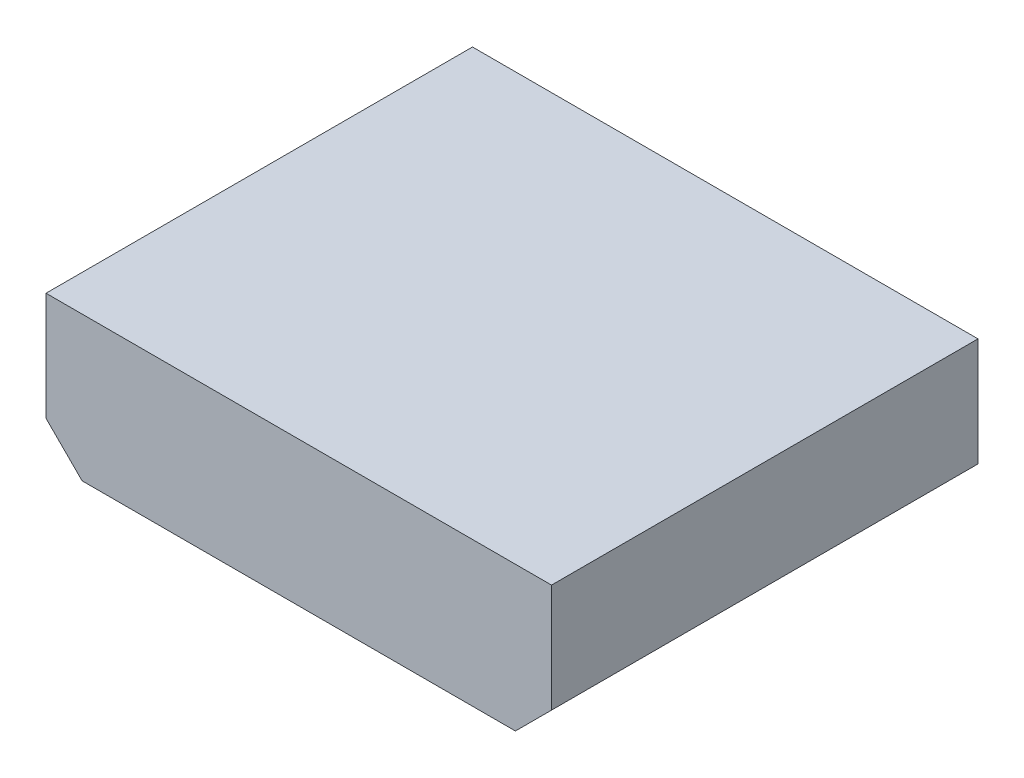
from build123d import *

# Parameters (mm, degrees)
COMPONENT_OUTLINE_DEPTH = 15
SKETCH2_R               = 0.25
EXTRUDE_1_DEPTH         = 2
SKETCH3_R               = 0.25
EXTRUDE_2_DEPTH         = 2
SKETCH4_R               = 0.25
EXTRUDE_3_DEPTH         = 2
SKETCH5_R               = 0.25
EXTRUDE_4_DEPTH         = 2


with BuildPart() as part:
    # Sketch1 → Component_Outline (new body)
    with BuildSketch(Plane.XY):
        Polygon((-5.08, 2.54), (-5.08, -1.27), (-3.81, -2.54), (11.43, -2.54), (12.7, -1.27), (12.7, 2.54), align=None)
    extrude(amount=COMPONENT_OUTLINE_DEPTH)


with BuildPart() as body_2:
    # Sketch2 → Extrude 1 (new body)
    with BuildSketch(Plane.XY):
        Circle(SKETCH2_R)
    extrude(amount=-EXTRUDE_1_DEPTH)


with BuildPart() as body_3:
    # Sketch3 → Extrude 2 (new body)
    with BuildSketch(Plane.XY):
        with Locations((2.54, 0)):
            Circle(SKETCH3_R)
    extrude(amount=-EXTRUDE_2_DEPTH)


with BuildPart() as body_4:
    # Sketch4 → Extrude 3 (new body)
    with BuildSketch(Plane.XY):
        with Locations((5.08, 0)):
            Circle(SKETCH4_R)
    extrude(amount=-EXTRUDE_3_DEPTH)


with BuildPart() as body_5:
    # Sketch5 → Extrude 4 (new body)
    with BuildSketch(Plane.XY):
        with Locations((7.62, 0)):
            Circle(SKETCH5_R)
    extrude(amount=-EXTRUDE_4_DEPTH)


solid = Compound([part.part, body_2.part, body_3.part, body_4.part, body_5.part])
